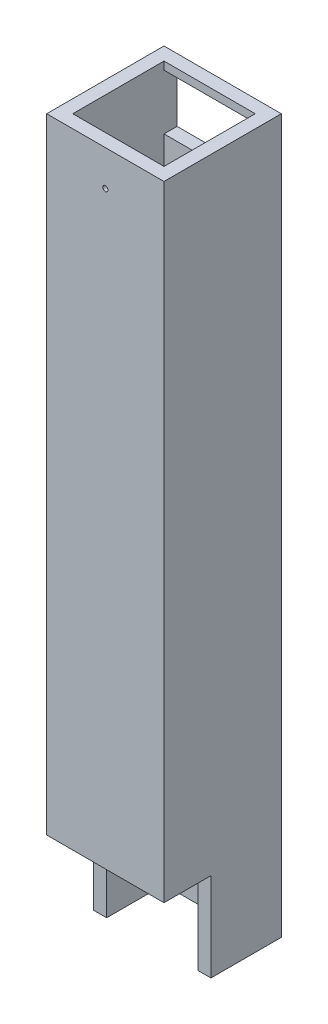
from build123d import *

# Parameters (mm, degrees)
CROQUIS1_W              = 45
CROQUIS1_H              = 45
SALIENTE_EXTRUIR1_DEPTH = 300
CROQUIS4_W              = 18
CROQUIS4_H              = 34
CORTAR_EXTRUIR2_DEPTH   = 46
CROQUIS8_W              = 35
CROQUIS8_H              = 35
CORTAR_EXTRUIR3_DEPTH   = 301
CROQUIS9_W              = 35
CROQUIS9_H              = 21.174410022
CORTAR_EXTRUIR4_DEPTH   = 10
CROQUIS10_R             = 1
CORTAR_EXTRUIR5_DEPTH   = 10
CROQUIS11_W             = 45
CROQUIS11_H             = 26.387879272
CORTAR_EXTRUIR6_DEPTH   = 46


with BuildPart() as part:
    # Croquis1 → Saliente-Extruir1 (new body)
    with BuildSketch(Plane(origin=(0, 0, 0), x_dir=(1, 0, 0), z_dir=(0, 1, 0))):
        Rectangle(CROQUIS1_W, CROQUIS1_H)
    extrude(amount=SALIENTE_EXTRUIR1_DEPTH)

    # Croquis4 → Cortar-Extruir2 (cut, through all)
    with BuildSketch(Plane.ZY.offset(22.5)):
        with Locations((13.5, 17)):
            Rectangle(CROQUIS4_W, CROQUIS4_H)
    extrude(amount=-CORTAR_EXTRUIR2_DEPTH, mode=Mode.SUBTRACT)

    # Croquis8 → Cortar-Extruir3 (cut, through all)
    with BuildSketch(Plane(origin=(0, 300, 0), x_dir=(1, 0, 0), z_dir=(0, 1, 0))):
        Rectangle(CROQUIS8_W, CROQUIS8_H)
    extrude(amount=-CORTAR_EXTRUIR3_DEPTH, mode=Mode.SUBTRACT)

    # Croquis9 → Cortar-Extruir4 (cut)
    with BuildSketch(Plane(origin=(0, 0, -22.5), x_dir=(-1, 0, 0), z_dir=(0, 0, -1))):
        with Locations((0, 260)):
            Rectangle(CROQUIS9_W, CROQUIS9_H)
    extrude(amount=-CORTAR_EXTRUIR4_DEPTH, mode=Mode.SUBTRACT)

    # Croquis10 → Cortar-Extruir5 (cut)
    with BuildSketch(Plane.XY.offset(22.5)):
        with Locations((0, 260)):
            Circle(CROQUIS10_R)
    extrude(amount=-CORTAR_EXTRUIR5_DEPTH, mode=Mode.SUBTRACT)

    # Croquis11 → Cortar-Extruir6 (cut, through all)
    with BuildSketch(Plane.XY.offset(22.5)):
        with Locations((0, 286.806060364)):
            Rectangle(CROQUIS11_W, CROQUIS11_H)
    extrude(amount=-CORTAR_EXTRUIR6_DEPTH, mode=Mode.SUBTRACT)


solid = part.part
